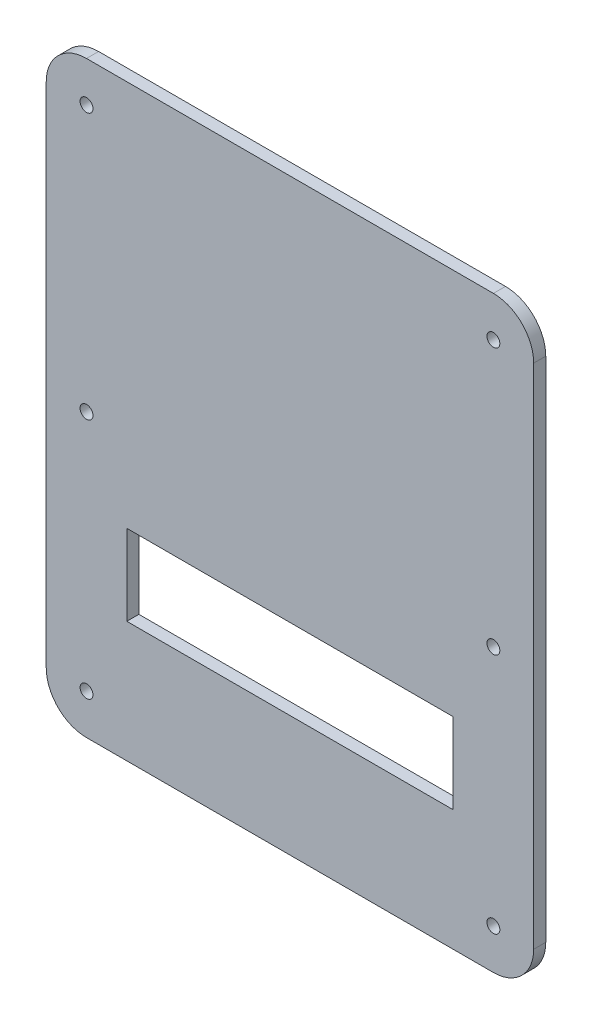
from build123d import *

# Parameters (mm, degrees)
SKETCH_1_W          = 121
SKETCH_1_H          = 146
EXTRUDE_1_DEPTH     = 3
FILLET_1_R          = 10
SKETCH_2_R          = 1.6
CUT_EXTRUDE_1_DEPTH = 4
SKETCH_3_W          = 81
SKETCH_3_H          = 20
CUT_EXTRUDE_2_DEPTH = 4


with BuildPart() as part:
    # Sketch 1 → ﾎﾞｽ - 押し出し1 (new body)
    with BuildSketch(Plane.XY):
        with Locations((60.5, 73)):
            Rectangle(SKETCH_1_W, SKETCH_1_H)
    extrude(amount=EXTRUDE_1_DEPTH)

    # ﾌｨﾚｯﾄ1
    fillet_1_edges = [part.edges().sort_by_distance(p)[0] for p in [
        (0, 146, 1.5),
        (121, 146, 1.5),
        (121, 0, 1.5),
        (0, 0, 1.5),
    ]]
    fillet(fillet_1_edges, radius=FILLET_1_R)

    # ｽｹｯﾁ2 → ｶｯﾄ - 押し出し1 (cut, through all)
    with BuildSketch(Plane.XY.offset(3)):
        with Locations((10, 136)):
            Circle(SKETCH_2_R)
        with Locations((10, 70.035204196)):
            Circle(SKETCH_2_R)
        with Locations((111, 136)):
            Circle(SKETCH_2_R)
        with Locations((111, 70)):
            Circle(SKETCH_2_R)
        with Locations((111, 10)):
            Circle(SKETCH_2_R)
        with Locations((10, 10)):
            Circle(SKETCH_2_R)
    extrude(amount=-CUT_EXTRUDE_1_DEPTH, mode=Mode.SUBTRACT)

    # ｽｹｯﾁ3 → ｶｯﾄ - 押し出し2 (cut, through all)
    with BuildSketch(Plane.XY.offset(3)):
        with Locations((60.5, 40)):
            Rectangle(SKETCH_3_W, SKETCH_3_H)
    extrude(amount=-CUT_EXTRUDE_2_DEPTH, mode=Mode.SUBTRACT)


solid = part.part
